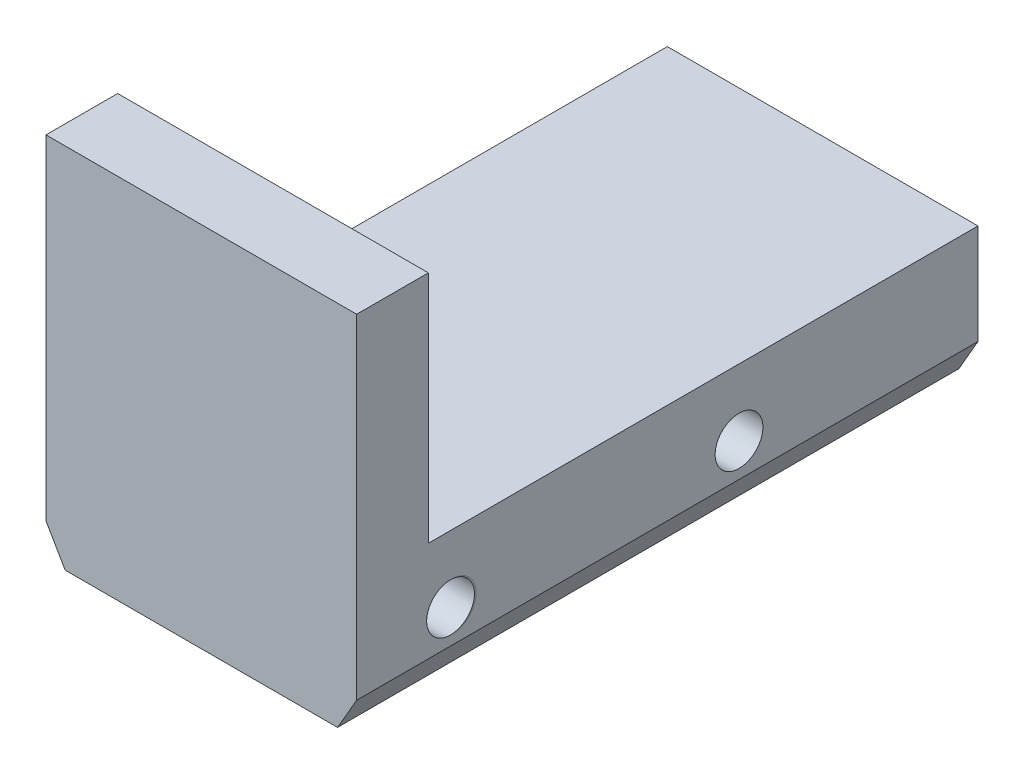
from build123d import *

# Parameters (mm, degrees)
SKETCH_1_W          = 13
SKETCH_1_H          = 26
EXTRUDE_1_DEPTH     = 5.57372
SKETCH_2_W          = 13
SKETCH_2_H          = 3
EXTRUDE_2_DEPTH     = 9.8
SKETCH_4_R          = 1
CUT_EXTRUDE_1_DEPTH = 14
CHAMFER_2_SIZE      = 0.8
CHAMFER_2_SIZE2     = 1.385640646
SKETCH_5_R          = 1
EXTRUDE_3_DEPTH     = 13
SKETCH_6_R          = 1
CUT_EXTRUDE_2_DEPTH = 14


with BuildPart() as part:
    # ｽｹｯﾁ1 → ﾎﾞｽ - 押し出し1 (new body)
    with BuildSketch(Plane(origin=(0, 0, 0), x_dir=(1, 0, 0), z_dir=(0, 1, 0))):
        with Locations((6.5, 13)):
            Rectangle(SKETCH_1_W, SKETCH_1_H)
    extrude(amount=EXTRUDE_1_DEPTH)

    # ｽｹｯﾁ2 → ﾎﾞｽ - 押し出し2 (add)
    with BuildSketch(Plane(origin=(0, 5.57372, 0), x_dir=(1, 0, 0), z_dir=(0, 1, 0))):
        with Locations((6.5, 1.5)):
            Rectangle(SKETCH_2_W, SKETCH_2_H)
    extrude(amount=EXTRUDE_2_DEPTH)

    # ｽｹｯﾁ4 → ｶｯﾄ - 押し出し1 (cut, through all)
    with BuildSketch(Plane.ZY):
        with Locations((-16, 2.78686)):
            Circle(SKETCH_4_R)
        with Locations((-4, 2.78686)):
            Circle(SKETCH_4_R)
    extrude(amount=-CUT_EXTRUDE_1_DEPTH, mode=Mode.SUBTRACT)

    # 面取り2
    chamfer_2_edges = [part.edges().sort_by_distance(p)[0] for p in [
        (13, 0, -13),
        (0, 0, -13),
    ]]
    chamfer_2_side = [part.faces().sort_by_distance(p)[0] for p in [
        (6.5, 0, -13),
    ]]
    chamfer(chamfer_2_edges, length=CHAMFER_2_SIZE, length2=CHAMFER_2_SIZE2, reference=chamfer_2_side[0])

    # ｽｹｯﾁ5 → ﾎﾞｽ - 押し出し3 (add, through all)
    with BuildSketch(Plane.ZY):
        with Locations((-4, 2.78686)):
            Circle(SKETCH_5_R)
    extrude(amount=-EXTRUDE_3_DEPTH)

    # ｽｹｯﾁ6 → ｶｯﾄ - 押し出し2 (cut, through all)
    with BuildSketch(Plane.ZY):
        with Locations((-3.92837, 2.78686)):
            Circle(SKETCH_6_R)
    extrude(amount=-CUT_EXTRUDE_2_DEPTH, mode=Mode.SUBTRACT)


solid = part.part
